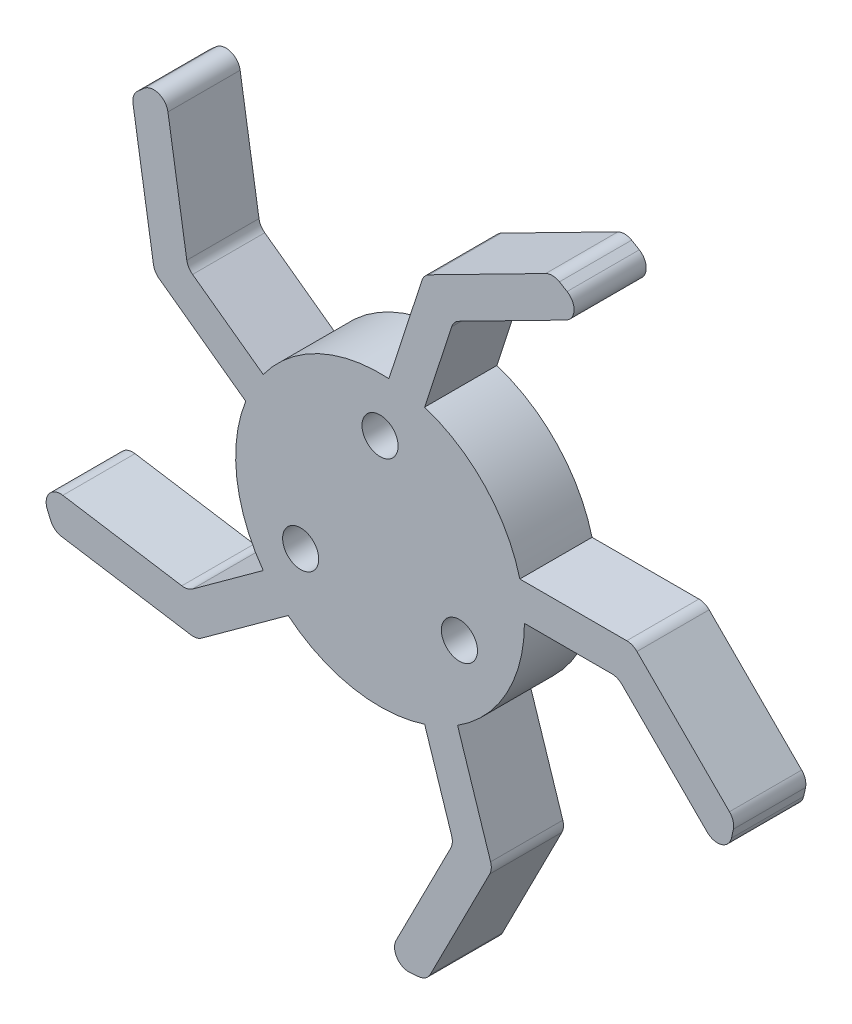
from build123d import *

# Parameters (mm, degrees)
SKETCH1_R                = 25.4
HUB_MAIN_DEPTH           = 12.7
SKETCH2_R                = 3.175
HUB_BOLT_HOLES_DEPTH     = 13.7
CIRPATTERN1_COUNT        = 3
LEG_DEPTH                = 12.7
FILLET1_R                = 2.54
CIRPATTERN2_COUNT        = 5
FILLET1_OF_CIRPATTERN2_R = 2.54


with BuildPart() as part:
    # Sketch1 → Hub main (new body)
    with BuildSketch(Plane.XY):
        Circle(SKETCH1_R)
    extrude(amount=HUB_MAIN_DEPTH)

    # Sketch2 → Hub bolt holes (cut, through all)
    with BuildSketch(Plane.XY.offset(12.7)):
        with Locations((0, 15.875)):
            Circle(SKETCH2_R)
    hub_bolt_holes = extrude(amount=-HUB_BOLT_HOLES_DEPTH, mode=Mode.SUBTRACT)

    # CirPattern1: Hub bolt holes ×3 about axis
    cirpattern1_axis = Axis((0, -0.251984127, 0), (0, 0, 1))
    for i in range(1, CIRPATTERN1_COUNT):
        add(hub_bolt_holes.rotate(cirpattern1_axis, i * 360 / CIRPATTERN1_COUNT), mode=Mode.SUBTRACT)

    # Sketch4 → leg (add)
    with BuildSketch(Plane.XY.offset(12.7)):
        with BuildLine():
            Line((24.593444248, 6.35), (44.45, 6.35))
            Line((44.45, 6.35), (62.426544532, -11.626544532))
            ThreePointArc((62.426544532, -11.626544532), (61.641094588, -15.252064058), (60.645274989, -18.82553111))
            Line((60.645274989, -18.82553111), (41.819743879, 0))
            Line((41.819743879, 0), (25.4, 0))
            ThreePointArc((25.4, 0), (25.197554285, 3.200509029), (24.593444248, 6.35))
        make_face()
    leg = extrude(amount=-LEG_DEPTH)

    # Fillet1
    fillet1_edges = [part.edges().sort_by_distance(p)[0] for p in [
        (41.819743879, 0, 6.35),
        (44.45, 6.35, 6.35),
        (62.426544532, -11.626544532, 6.35),
        (60.645274989, -18.82553111, 6.35),
    ]]
    fillet(fillet1_edges, radius=FILLET1_R)

    # CirPattern2: leg ×5 about axis
    cirpattern2_axis = Axis((0, 0, 0), (0, 0, 1))
    for i in range(1, CIRPATTERN2_COUNT):
        add(leg.rotate(cirpattern2_axis, i * 360 / CIRPATTERN2_COUNT))

    # Fillet1 of CirPattern2
    fillet1_of_cirpattern2_edges = [part.edges().sort_by_distance(p)[0] for p in [
        (12.923011559, 39.772939926, 6.35),
        (7.696596521, 44.236720064, 6.35),
        (30.3483641, 55.778372121, 6.35),
        (36.644564635, 51.859674919, 6.35),
        (-33.832883498, 24.581028707, 6.35),
        (-39.693241752, 20.98979655, 6.35),
        (-43.670224016, 46.09947434, 6.35),
        (-37.997688541, 50.876572855, 6.35),
        (-33.832883498, -24.581028707, 6.35),
        (-32.228369048, -31.264312379, 6.35),
        (-57.338046838, -27.287330115, 6.35),
        (-60.128427647, -20.416223664, 6.35),
        (12.923011559, -39.772939926, 6.35),
        (19.775014278, -40.312204235, 6.35),
        (8.233362221, -62.963971814, 6.35),
        (0.836276565, -63.494493001, 6.35),
    ]]
    fillet(fillet1_of_cirpattern2_edges, radius=FILLET1_OF_CIRPATTERN2_R)


solid = part.part
